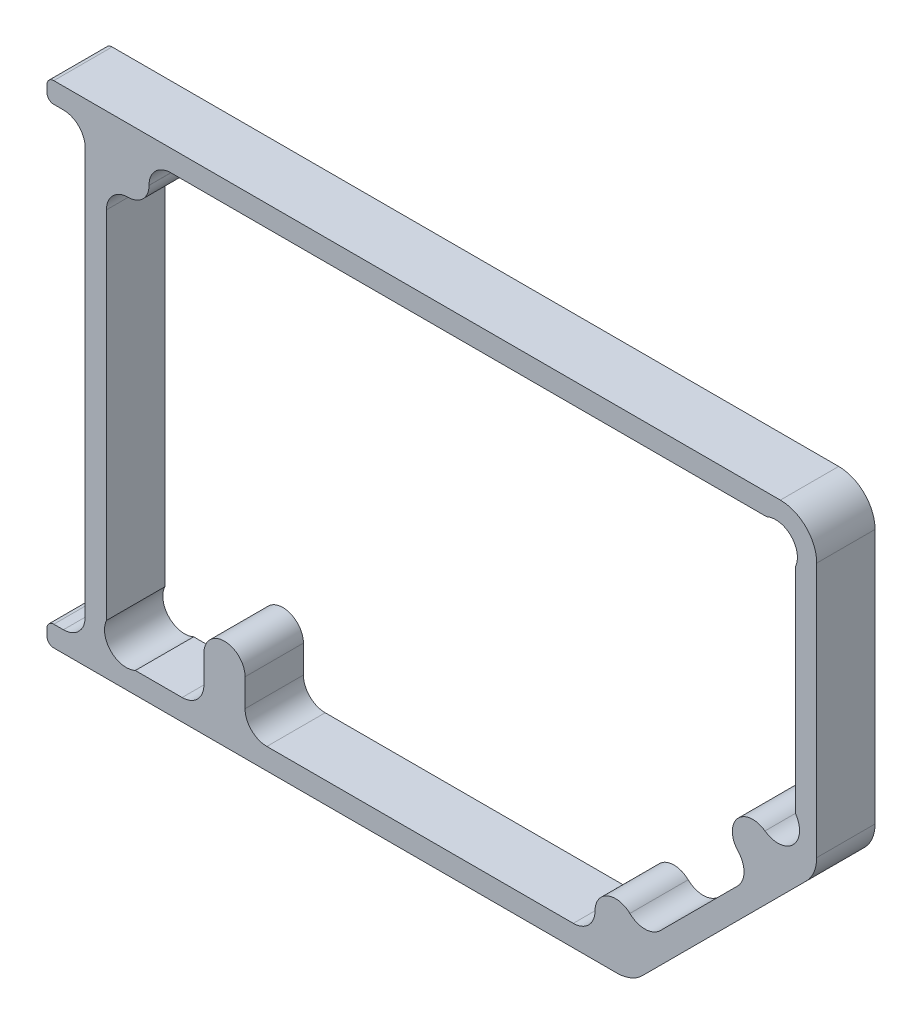
from build123d import *

# Parameters (mm, degrees)
BOSS_EXTRUDE1_DEPTH = 8.5


with BuildPart() as part:
    # Sketch1 → Boss-Extrude1 (new body)
    with BuildSketch(Plane.XY):
        with BuildLine():
            Line((-8.87, -1.3), (-8.87, -2.3))
            ThreePointArc((-8.87, -2.3), (-8.577106781, -3.007106781), (-7.87, -3.3))
            Line((-7.87, -3.3), (74.171572667, -3.3))
            ThreePointArc((74.171572667, -3.3), (76.199795144, -2.896561433), (77.919239112, -1.747665644))
            Line((77.919239112, -1.747665644), (101.747665711, 22.080760955))
            ThreePointArc((101.747665711, 22.080760955), (102.896561433, 23.800204856), (103.3, 25.828427238))
            Line((103.3, 25.828427238), (103.3, 63))
            ThreePointArc((103.3, 63), (101.74766594, 66.74766594), (98, 68.3))
            Line((98, 68.3), (-7.87, 68.3))
            ThreePointArc((-7.87, 68.3), (-8.577106781, 68.007106781), (-8.87, 67.3))
            Line((-8.87, 67.3), (-8.87, 66.3))
            ThreePointArc((-8.87, 66.3), (-8.577106781, 65.592893219), (-7.87, 65.3))
            Line((-7.87, 65.3), (-6.475, 65.3))
            ThreePointArc((-6.475, 65.3), (-4.22993597, 64.37006403), (-3.3, 62.125))
            Line((-3.3, 62.125), (-3.3, 2.875))
            ThreePointArc((-3.3, 2.875), (-4.22993597, 0.62993597), (-6.475, -0.3))
            Line((-6.475, -0.3), (-7.87, -0.3))
            ThreePointArc((-7.87, -0.3), (-8.577106781, -0.592893219), (-8.87, -1.3))
        make_face()
        with BuildLine():
            Line((100.2, 29.856417462), (100.2, 60.994582891))
            ThreePointArc((100.2, 60.994582891), (99.555634919, 64.555634919), (95.994582891, 65.2))
            Line((95.994582891, 65.2), (9.175, 65.2))
            ThreePointArc((9.175, 65.2), (6.92993597, 64.27006403), (6, 62.025))
            Line((6, 62.025), (6, 62))
            ThreePointArc((6, 62), (5.121320344, 59.878679656), (3, 59))
            Line((3, 59), (2.975, 59))
            ThreePointArc((2.975, 59), (0.72993597, 58.07006403), (-0.2, 55.825))
            Line((-0.2, 55.825), (-0.2, 4.005417109))
            ThreePointArc((-0.2, 4.005417109), (0.444365081, 0.444365081), (4.005417109, -0.2))
            Line((4.005417109, -0.2), (10.825, -0.2))
            ThreePointArc((10.825, -0.2), (13.07006403, 0.72993597), (14, 2.975))
            Line((14, 2.975), (14, 7))
            ThreePointArc((14, 7), (17, 10), (20, 7))
            Line((20, 7), (20, 2.975))
            ThreePointArc((20, 2.975), (20.92993597, 0.72993597), (23.175, -0.2))
            Line((23.175, -0.2), (67.825, -0.2))
            ThreePointArc((67.825, -0.2), (70.07006403, 0.72993597), (71, 2.975))
            Line((71, 2.975), (71, 3))
            ThreePointArc((71, 3), (72.819133757, 5.757817056), (76.070369945, 5.171075377))
            ThreePointArc((76.070369945, 5.171075377), (78.299195815, 4.294020465), (80.5065755, 5.223732787))
            Line((80.5065755, 5.223732787), (91.776267213, 16.4934245))
            ThreePointArc((91.776267213, 16.4934245), (92.705979535, 18.700804185), (91.828924623, 20.929630055))
            ThreePointArc((91.828924623, 20.929630055), (91.741164129, 24.974249353), (95.761133603, 25.428663919))
            ThreePointArc((95.761133603, 25.428663919), (98.192543935, 24.875137086), (100.273869597, 26.248538573))
            ThreePointArc((100.273869597, 26.248538573), (100.79933472, 28.063992887), (100.2, 29.856417462))
        make_face(mode=Mode.SUBTRACT)
    extrude(amount=BOSS_EXTRUDE1_DEPTH)


solid = part.part
